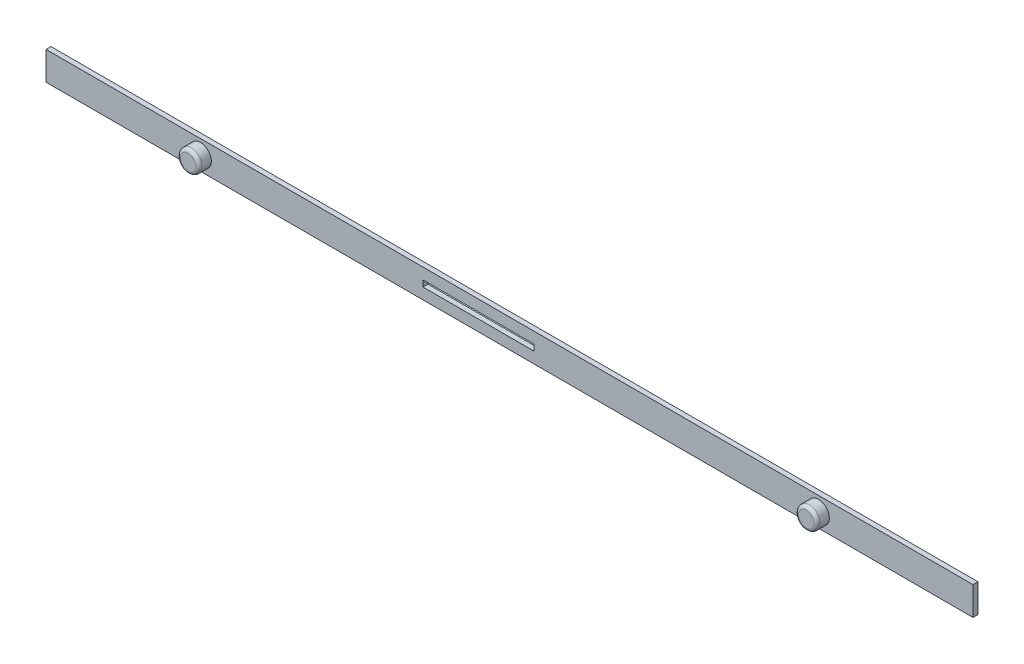
from build123d import *

# Parameters (mm, degrees)
SKICA2_W                = 150
SKICA2_H                = 4.6
SKICA2_W_2              = 18
SKICA2_H_2              = 1
P_IDAT_VYSUNUT_M2_DEPTH = 0.8
SKICA3_R                = 1.75
P_IDAT_VYSUNUT_M3_DEPTH = 2
ZAOBLIT1_R              = 0.5


with BuildPart() as part:
    # Skica2 → Přidat vysunutím2 (new body)
    with BuildSketch(Plane.XY):
        Rectangle(SKICA2_W, SKICA2_H)
        with Locations((-5, 0)):
            Rectangle(SKICA2_W_2, SKICA2_H_2, mode=Mode.SUBTRACT)
    extrude(amount=P_IDAT_VYSUNUT_M2_DEPTH)

    # Skica3 → Přidat vysunutím3 (add)
    with BuildSketch(Plane.XY.offset(0.8)):
        with Locations((-50, 0)):
            Circle(SKICA3_R)
        with Locations((50, 0)):
            Circle(SKICA3_R)
    extrude(amount=P_IDAT_VYSUNUT_M3_DEPTH)

    # Zaoblit1
    zaoblit1_edges = [part.edges().sort_by_distance(p)[0] for p in [
        (-51.75, 0, 2.8),
        (48.25, 0, 2.8),
    ]]
    fillet(zaoblit1_edges, radius=ZAOBLIT1_R)


solid = part.part
